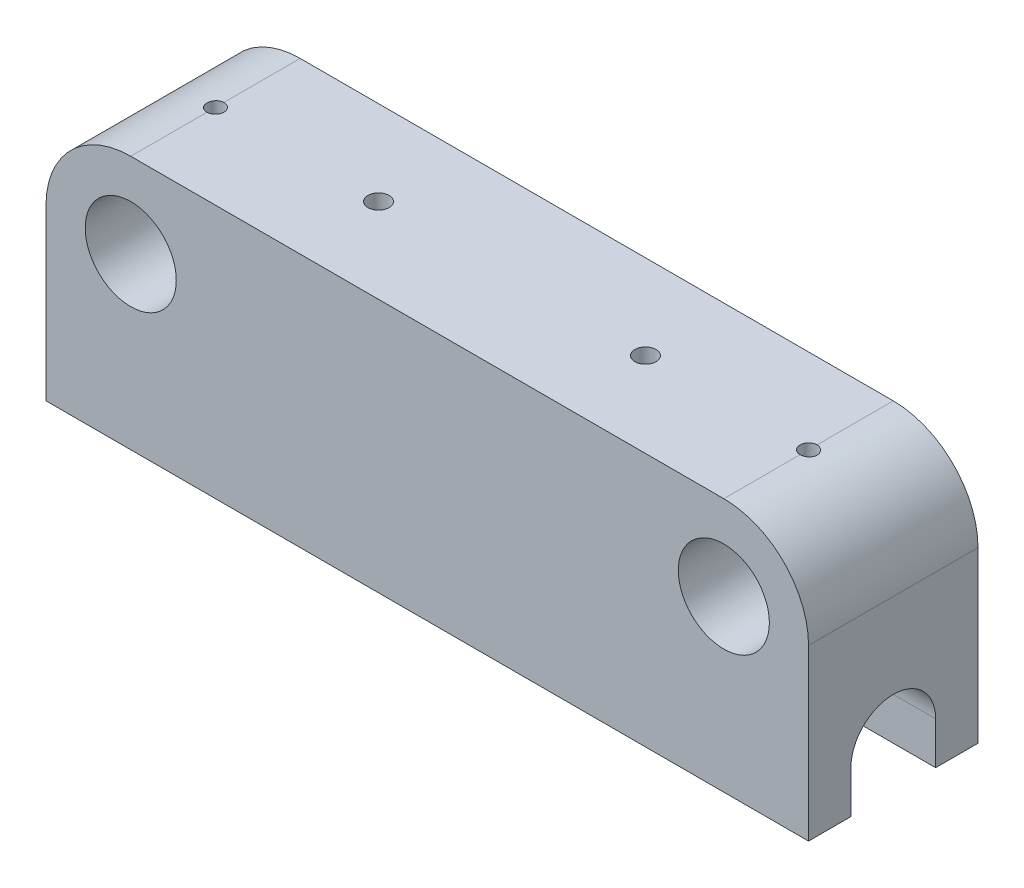
from build123d import *

# Parameters (mm, degrees)
SKETCH1_R                       = 10.75
BOSS_EXTRUDE1_DEPTH             = 40
BOSS_EXTRUDE2_REACH             = 92
BOSS_EXTRUDE2_DIRECTION_2_REACH = 92
SKETCH5_R                       = 2.5
CUT_EXTRUDE1_DEPTH              = 54.696523
CUT_EXTRUDE3_REACH              = 62
SKETCH8_R                       = 2


with BuildPart() as part:
    # Sketch1 → Boss-Extrude1 (new body)
    with BuildSketch(Plane.XY):
        with BuildLine():
            Line((-70, 54.696522502), (70, 54.696522502))
            ThreePointArc((70, 54.696522502), (84.142135624, 48.838658125), (90, 34.696522502))
            Line((90, 34.696522502), (90, 14.696522502))
            Line((90, 14.696522502), (-90, 14.696522502))
            Line((-90, 14.696522502), (-90, 34.696522502))
            ThreePointArc((-90, 34.696522502), (-84.142135624, 48.838658125), (-70, 54.696522502))
        make_face()
        with Locations((70, 34.696522502)):
            Circle(SKETCH1_R, mode=Mode.SUBTRACT)
        with Locations((-70, 34.696522502)):
            Circle(SKETCH1_R, mode=Mode.SUBTRACT)
    extrude(amount=BOSS_EXTRUDE1_DEPTH)

    # Boss-Extrude2: up to this face of the body (flat: up to its plane)
    boss_extrude2_end = Plane(part.part.faces().sort_by_distance((90, 24.696522502, 20))[0])
    # Sketch4 → Boss-Extrude2 (add, up to the picked face)
    with BuildSketch(Plane(origin=(0, 0, 0), x_dir=(0, 0, -1), z_dir=(1, 0, 0)), mode=Mode.PRIVATE) as boss_extrude2_sk1:
        with BuildLine():
            Line((0, -5.303477498), (0, 14.696522502))
            Line((0, 14.696522502), (-20, 14.696522502))
            ThreePointArc((-20, 14.696522502), (-12.928932188, 11.767590313), (-10, 4.696522502))
            Line((-10, 4.696522502), (-10, -5.303477498))
            Line((-10, -5.303477498), (0, -5.303477498))
        make_face()
    boss_extrude2_tool1 = split(extrude(boss_extrude2_sk1.sketch, amount=BOSS_EXTRUDE2_REACH, mode=Mode.PRIVATE), bisect_by=boss_extrude2_end, keep=Keep.BOTH, mode=Mode.PRIVATE)
    add(boss_extrude2_tool1.solids().sort_by_distance((0, 5.449103, 5.700966))[0])
    # Sketch4 → Boss-Extrude2 (add, up to the picked face)
    with BuildSketch(Plane(origin=(0, 0, 0), x_dir=(0, 0, -1), z_dir=(1, 0, 0)), mode=Mode.PRIVATE) as boss_extrude2_sk2:
        with BuildLine():
            ThreePointArc((-30, 4.696522502), (-27.071067812, 11.767590313), (-20, 14.696522502))
            Line((-20, 14.696522502), (-40, 14.696522502))
            Line((-40, 14.696522502), (-40, -5.303477498))
            Line((-40, -5.303477498), (-30, -5.303477498))
            Line((-30, -5.303477498), (-30, 4.696522502))
        make_face()
    boss_extrude2_tool2 = split(extrude(boss_extrude2_sk2.sketch, amount=BOSS_EXTRUDE2_REACH, mode=Mode.PRIVATE), bisect_by=boss_extrude2_end, keep=Keep.BOTH, mode=Mode.PRIVATE)
    add(boss_extrude2_tool2.solids().sort_by_distance((0, 5.449103, 34.299034))[0])

    # Boss-Extrude2 direction 2: up to this face of the body (flat: up to its plane)
    boss_extrude2_direction_2_end = Plane(part.part.faces().sort_by_distance((-90, 24.696522502, 20))[0])
    # Sketch4 → Boss-Extrude2 direction 2 (add, up to the picked face)
    with BuildSketch(Plane(origin=(0, 0, 0), x_dir=(0, 0, -1), z_dir=(1, 0, 0)), mode=Mode.PRIVATE) as boss_extrude2_direction_2_sk1:
        with BuildLine():
            Line((0, -5.303477498), (0, 14.696522502))
            Line((0, 14.696522502), (-20, 14.696522502))
            ThreePointArc((-20, 14.696522502), (-12.928932188, 11.767590313), (-10, 4.696522502))
            Line((-10, 4.696522502), (-10, -5.303477498))
            Line((-10, -5.303477498), (0, -5.303477498))
        make_face()
    boss_extrude2_direction_2_tool1 = split(extrude(boss_extrude2_direction_2_sk1.sketch, amount=-BOSS_EXTRUDE2_DIRECTION_2_REACH, mode=Mode.PRIVATE), bisect_by=boss_extrude2_direction_2_end, keep=Keep.BOTH, mode=Mode.PRIVATE)
    add(boss_extrude2_direction_2_tool1.solids().sort_by_distance((0, 5.449103, 5.700966))[0])
    # Sketch4 → Boss-Extrude2 direction 2 (add, up to the picked face)
    with BuildSketch(Plane(origin=(0, 0, 0), x_dir=(0, 0, -1), z_dir=(1, 0, 0)), mode=Mode.PRIVATE) as boss_extrude2_direction_2_sk2:
        with BuildLine():
            ThreePointArc((-30, 4.696522502), (-27.071067812, 11.767590313), (-20, 14.696522502))
            Line((-20, 14.696522502), (-40, 14.696522502))
            Line((-40, 14.696522502), (-40, -5.303477498))
            Line((-40, -5.303477498), (-30, -5.303477498))
            Line((-30, -5.303477498), (-30, 4.696522502))
        make_face()
    boss_extrude2_direction_2_tool2 = split(extrude(boss_extrude2_direction_2_sk2.sketch, amount=-BOSS_EXTRUDE2_DIRECTION_2_REACH, mode=Mode.PRIVATE), bisect_by=boss_extrude2_direction_2_end, keep=Keep.BOTH, mode=Mode.PRIVATE)
    add(boss_extrude2_direction_2_tool2.solids().sort_by_distance((0, 5.449103, 34.299034))[0])

    # Sketch5 → Cut-Extrude1 (cut)
    with BuildSketch(Plane(origin=(0, 0, 0), x_dir=(1, 0, 0), z_dir=(0, 1, 0))):
        with Locations((-31.5, -20)):
            Circle(SKETCH5_R)
        with Locations((31.5, -20)):
            Circle(SKETCH5_R)
    extrude(amount=CUT_EXTRUDE1_DEPTH, mode=Mode.SUBTRACT)

    # Sketch8 → Cut-Extrude3 (cut, up to next)
    with BuildSketch(Plane(origin=(0, 54.696522502, 0), x_dir=(1, 0, 0), z_dir=(0, 1, 0)), mode=Mode.PRIVATE) as cut_extrude3_sk1:
        with Locations((-70, -20)):
            Circle(SKETCH8_R)
    cut_extrude3_tool1 = extrude(cut_extrude3_sk1.sketch, amount=-CUT_EXTRUDE3_REACH, mode=Mode.PRIVATE) & part.part
    add(cut_extrude3_tool1.solids().sort_by_distance((-70, 54.696523, 20))[0], mode=Mode.SUBTRACT)
    # Sketch8 → Cut-Extrude3 (cut, up to next)
    with BuildSketch(Plane(origin=(0, 54.696522502, 0), x_dir=(1, 0, 0), z_dir=(0, 1, 0)), mode=Mode.PRIVATE) as cut_extrude3_sk2:
        with Locations((70, -20)):
            Circle(SKETCH8_R)
    cut_extrude3_tool2 = extrude(cut_extrude3_sk2.sketch, amount=-CUT_EXTRUDE3_REACH, mode=Mode.PRIVATE) & part.part
    add(cut_extrude3_tool2.solids().sort_by_distance((70, 54.696523, 20))[0], mode=Mode.SUBTRACT)


solid = part.part
